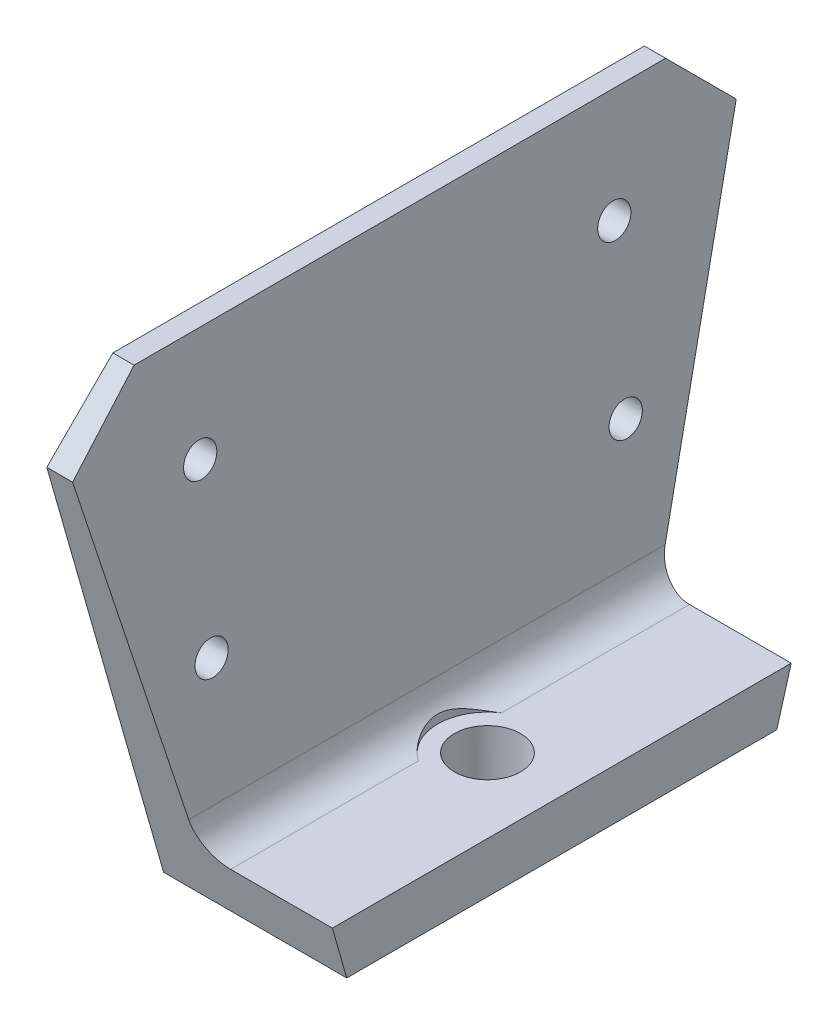
from build123d import *

# Parameters (mm, degrees)
SKETCH2_R               = 3.175
BOSS_EXTRUDE1_DEPTH     = 9.652
BOSS_EXTRUDE2_DEPTH     = 35.052
CUT_EXTRUDE1_DEPTH      = 117.316470579
CUT_EXTRUDE1_DEPTH_BACK = 117.316470579
FILLET1_R               = 6.35
CUT_EXTRUDE3_DEPTH      = 109.937280598
CUT_EXTRUDE3_DEPTH_BACK = 109.937280598
SKETCH5_R               = 6.35
SKETCH6_R               = 9.525
CUT_EXTRUDE4_DEPTH      = 109.937280598


with BuildPart() as part:
    # Sketch2 → Boss-Extrude1 (new body)
    with BuildSketch(Plane(origin=(0, 0, 0), x_dir=(0, 0, -1), z_dir=(1, 0, 0))):
        Polygon((41.148, 0), (63.5, 78.2912287), (50.8592287, 90.932), (-50.8592287, 90.932), (-63.5, 78.2912287), (-41.148, 0), align=None)
        with Locations((39.624, 70.358)):
            Circle(SKETCH2_R, mode=Mode.SUBTRACT)
        with Locations((39.624, 38.608)):
            Circle(SKETCH2_R, mode=Mode.SUBTRACT)
        with Locations((-39.624, 70.358)):
            Circle(SKETCH2_R, mode=Mode.SUBTRACT)
        with Locations((-39.624, 38.608)):
            Circle(SKETCH2_R, mode=Mode.SUBTRACT)
    extrude(amount=BOSS_EXTRUDE1_DEPTH)

    # Sketch2_6 → Boss-Extrude2 (add)
    with BuildSketch(Plane(origin=(0, 0, 0), x_dir=(0, 0, -1), z_dir=(1, 0, 0))):
        Polygon((41.148, 0), (43.903628026, 9.652), (-43.903628026, 9.652), (-41.148, 0), align=None)
    extrude(amount=BOSS_EXTRUDE2_DEPTH)

    # Sketch4 → Cut-Extrude1 (cut, two sides: drawn at the far end of the back side and taken through both)
    with BuildSketch(Plane.XY.offset(-CUT_EXTRUDE1_DEPTH_BACK)):
        Polygon((9.652, 9.652), (4.064, 90.932), (9.652, 90.932), align=None)
    extrude(amount=CUT_EXTRUDE1_DEPTH + CUT_EXTRUDE1_DEPTH_BACK, mode=Mode.SUBTRACT)

    # Fillet1
    fillet1_edges = [part.edges().sort_by_distance(p)[0] for p in [
        (9.652, 9.652, 0),
    ]]
    fillet(fillet1_edges, radius=FILLET1_R)

    # Sketch5 → Cut-Extrude3 (cut, two sides: drawn at the far end of the back side and taken through both)
    with BuildSketch(Plane(origin=(0, 9.652, 0), x_dir=(1, 0, 0), z_dir=(0, 1, 0)).offset(-CUT_EXTRUDE3_DEPTH_BACK)):
        with Locations((20.828, 0)):
            Circle(SKETCH5_R)
    extrude(amount=CUT_EXTRUDE3_DEPTH + CUT_EXTRUDE3_DEPTH_BACK, mode=Mode.SUBTRACT)

    # Sketch6 → Cut-Extrude4 (cut, through all)
    with BuildSketch(Plane(origin=(0, 9.652, 0), x_dir=(1, 0, 0), z_dir=(0, 1, 0))):
        with Locations((20.828, 0)):
            Circle(SKETCH6_R)
    extrude(amount=CUT_EXTRUDE4_DEPTH, mode=Mode.SUBTRACT)


solid = part.part
